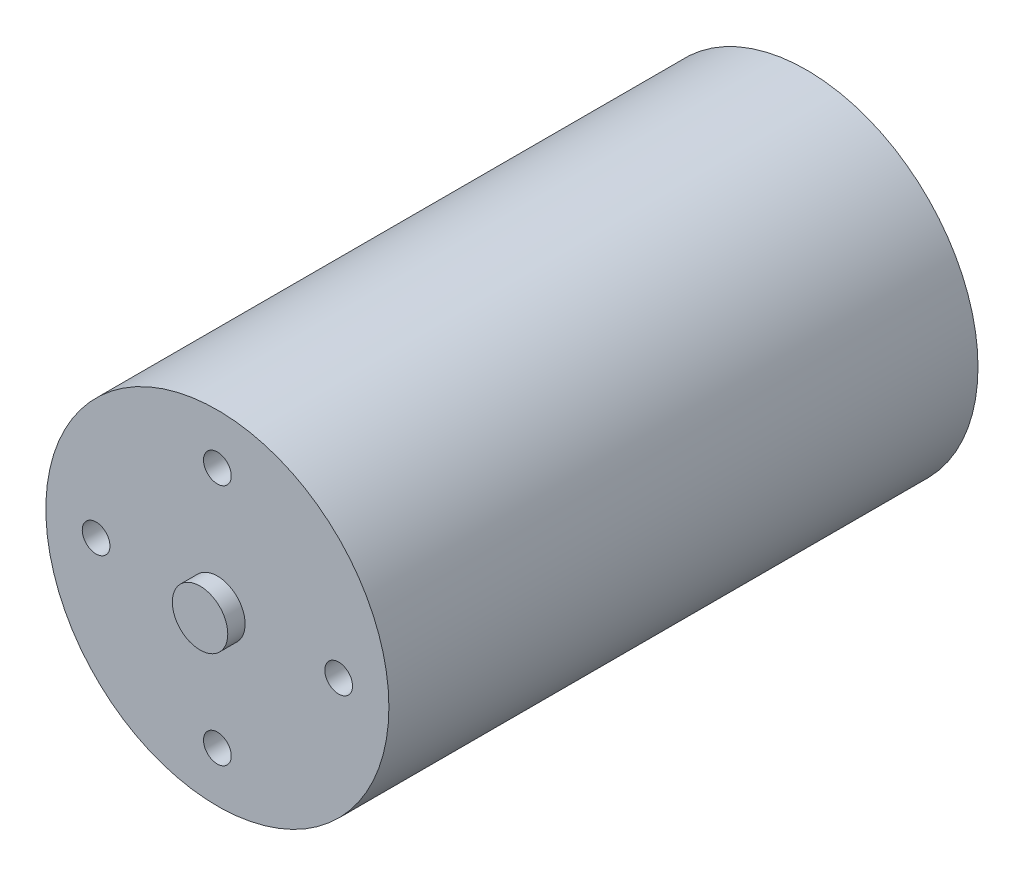
from build123d import *

# Parameters (mm, degrees)
SKETCH1_R           = 24.75
BOSS_EXTRUDE1_DEPTH = 42.5
SKETCH2_R           = 4
BOSS_EXTRUDE2_DEPTH = 2.5
SKETCH6_R           = 2
CUT_EXTRUDE3_DEPTH  = 5
CIRPATTERN1_COUNT   = 4
SKETCH5_R           = 2
CUT_EXTRUDE2_DEPTH  = 10
CIRPATTERN2_COUNT   = 4
SKETCH7_R           = 10.5
BOSS_EXTRUDE3_DEPTH = 5


with BuildPart() as part:
    # Sketch1 → Boss-Extrude1 (new body, symmetric)
    with BuildSketch(Plane.XY):
        Circle(SKETCH1_R)
    extrude(amount=BOSS_EXTRUDE1_DEPTH, both=True)

    # Sketch2 → Boss-Extrude2 (add)
    with BuildSketch(Plane.XY.offset(42.5)):
        Circle(SKETCH2_R)
    extrude(amount=BOSS_EXTRUDE2_DEPTH)

    # Sketch6 → Cut-Extrude3 (cut)
    with BuildSketch(Plane.XY.offset(42.5)):
        with Locations((0, 17.5)):
            Circle(SKETCH6_R)
    cut_extrude3 = extrude(amount=-CUT_EXTRUDE3_DEPTH, mode=Mode.SUBTRACT)

    # CirPattern1: Cut-Extrude3 ×4 about axis
    cirpattern1_axis = Axis((0, 0, 0), (0, 0, 1))
    for i in range(1, CIRPATTERN1_COUNT):
        add(cut_extrude3.rotate(cirpattern1_axis, i * 360 / CIRPATTERN1_COUNT), mode=Mode.SUBTRACT)

    # Sketch5 → Cut-Extrude2 (cut)
    with BuildSketch(Plane(origin=(0, 0, -42.5), x_dir=(-1, 0, 0), z_dir=(0, 0, -1))):
        with Locations((-17.5, 0)):
            Circle(SKETCH5_R)
    cut_extrude2 = extrude(amount=-CUT_EXTRUDE2_DEPTH, mode=Mode.SUBTRACT)

    # CirPattern2: Cut-Extrude2 ×4 about axis
    cirpattern2_axis = Axis((0, 0, 0), (0, 0, 1))
    for i in range(1, CIRPATTERN2_COUNT):
        add(cut_extrude2.rotate(cirpattern2_axis, i * 360 / CIRPATTERN2_COUNT), mode=Mode.SUBTRACT)

    # Sketch7 → Boss-Extrude3 (add)
    with BuildSketch(Plane(origin=(0, 0, -42.5), x_dir=(-1, 0, 0), z_dir=(0, 0, -1))):
        Circle(SKETCH7_R)
    extrude(amount=BOSS_EXTRUDE3_DEPTH)


solid = part.part
